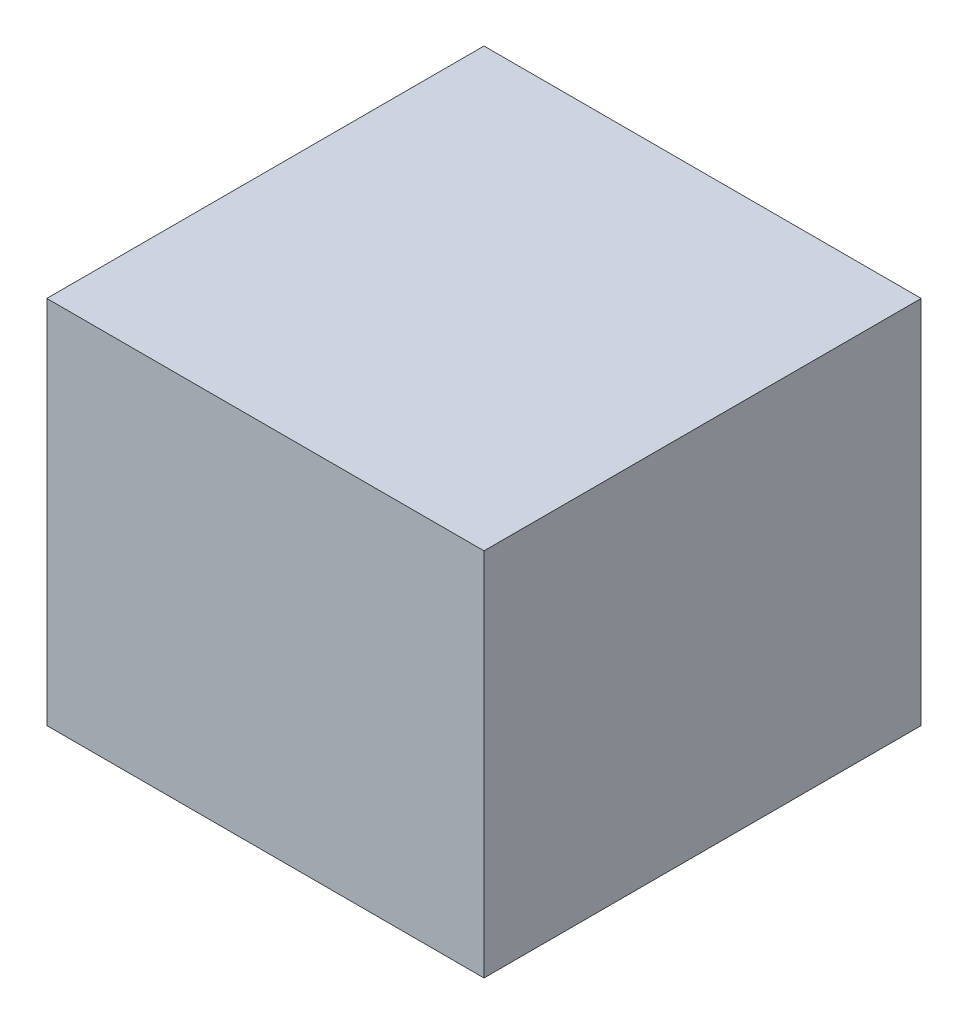
from build123d import *

# Parameters (mm, degrees)
SKETCH1_W           = 330.2
SKETCH1_H           = 330.2
BOSS_EXTRUDE1_DEPTH = 279.4


with BuildPart() as part:
    # Sketch1 → Boss-Extrude1 (new body)
    with BuildSketch(Plane(origin=(0, 0, 0), x_dir=(1, 0, 0), z_dir=(0, 1, 0))):
        with Locations((-165.1, 165.1)):
            Rectangle(SKETCH1_W, SKETCH1_H)
    extrude(amount=BOSS_EXTRUDE1_DEPTH)


solid = part.part
